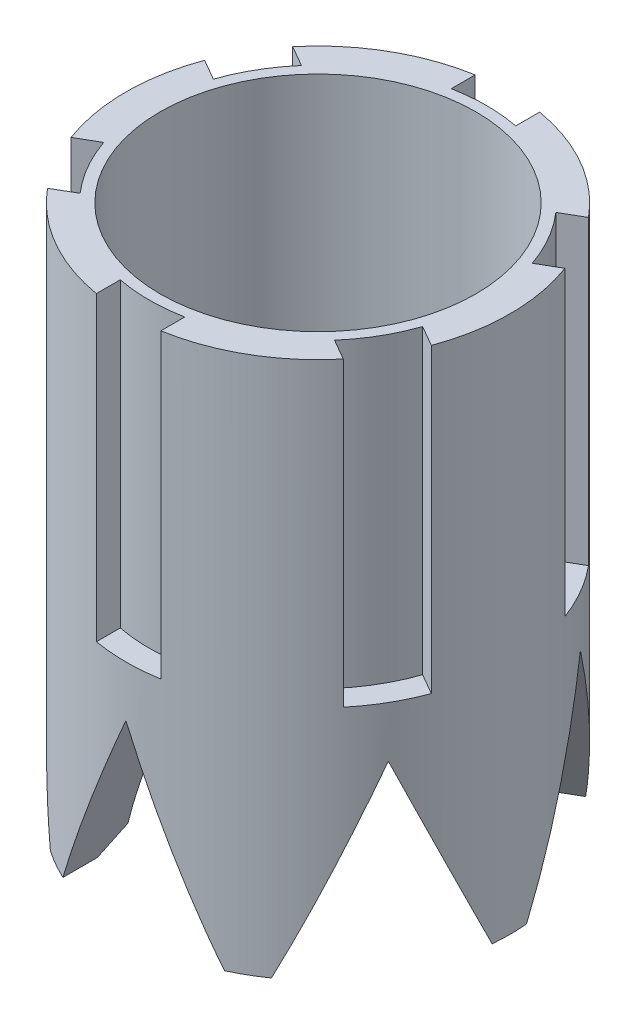
from build123d import *

# Parameters (mm, degrees)
SKETCH1_R           = 5.065
SKETCH1_R_2         = 3.67
BOSS_EXTRUDE1_DEPTH = 14.17
CUT_EXTRUDE1_DEPTH  = 7.95
SKETCH3_R           = 4.160986794
CUT_EXTRUDE2_DEPTH  = 7.59
CUT_EXTRUDE4_DEPTH  = 5.065
CIRPATTERN2_COUNT   = 6


with BuildPart() as part:
    # Sketch1 → Boss-Extrude1 (new body)
    with BuildSketch(Plane(origin=(0, 0, 0), x_dir=(1, 0, 0), z_dir=(0, 1, 0))):
        Circle(SKETCH1_R)
        Circle(SKETCH1_R_2, mode=Mode.SUBTRACT)
    extrude(amount=BOSS_EXTRUDE1_DEPTH)

    # Sketch2 → Cut-Extrude1 (cut)
    with BuildSketch(Plane(origin=(0, 14.17, 0), x_dir=(1, 0, 0), z_dir=(0, 1, 0))):
        with BuildLine():
            Line((-0.85, 4.362972037), (-0.85, 4.993167832))
            ThreePointArc((-0.85, 4.993167832), (0, 5.065), (0.85, 4.993167832))
            Line((0.85, 4.993167832), (0.85, 4.362972037))
            ThreePointArc((0.85, 4.362972037), (0, 4.445), (-0.85, 4.362972037))
        make_face()
        with BuildLine():
            Line((3.35344462, 2.917607612), (3.899210188, 3.232705509))
            ThreePointArc((3.899210188, 3.232705509), (4.38641867, 2.5325), (4.749210188, 1.760462323))
            Line((4.749210188, 1.760462323), (4.20344462, 1.445364426))
            ThreePointArc((4.20344462, 1.445364426), (3.84948292, 2.2225), (3.35344462, 2.917607612))
        make_face()
        with BuildLine():
            Line((4.20344462, -1.445364426), (4.749210188, -1.760462323))
            ThreePointArc((4.749210188, -1.760462323), (4.38641867, -2.5325), (3.899210188, -3.232705509))
            Line((3.899210188, -3.232705509), (3.35344462, -2.917607612))
            ThreePointArc((3.35344462, -2.917607612), (3.84948292, -2.2225), (4.20344462, -1.445364426))
        make_face()
        with BuildLine():
            Line((0.85, -4.362972037), (0.85, -4.993167832))
            ThreePointArc((0.85, -4.993167832), (0, -5.065), (-0.85, -4.993167832))
            Line((-0.85, -4.993167832), (-0.85, -4.362972037))
            ThreePointArc((-0.85, -4.362972037), (0, -4.445), (0.85, -4.362972037))
        make_face()
        with BuildLine():
            Line((-3.35344462, -2.917607612), (-3.899210188, -3.232705509))
            ThreePointArc((-3.899210188, -3.232705509), (-4.38641867, -2.5325), (-4.749210188, -1.760462323))
            Line((-4.749210188, -1.760462323), (-4.20344462, -1.445364426))
            ThreePointArc((-4.20344462, -1.445364426), (-3.84948292, -2.2225), (-3.35344462, -2.917607612))
        make_face()
        with BuildLine():
            Line((-4.20344462, 1.445364426), (-4.749210188, 1.760462323))
            ThreePointArc((-4.749210188, 1.760462323), (-4.38641867, 2.5325), (-3.899210188, 3.232705509))
            Line((-3.899210188, 3.232705509), (-3.35344462, 2.917607612))
            ThreePointArc((-3.35344462, 2.917607612), (-3.84948292, 2.2225), (-4.20344462, 1.445364426))
        make_face()
    extrude(amount=-CUT_EXTRUDE1_DEPTH, mode=Mode.SUBTRACT)

    # Sketch3 → Cut-Extrude2 (cut)
    with BuildSketch(Plane(origin=(0, 14.17, 0), x_dir=(1, 0, 0), z_dir=(0, 1, 0))):
        Circle(SKETCH3_R)
    extrude(amount=-CUT_EXTRUDE2_DEPTH, mode=Mode.SUBTRACT)

    # Sketch5 → Cut-Extrude4 (cut)
    with BuildSketch(Plane.XY):
        Polygon((0, 4.88), (-2.13, 0), (2.13, 0), align=None)
    cut_extrude4 = extrude(amount=-CUT_EXTRUDE4_DEPTH, mode=Mode.SUBTRACT)

    # CirPattern2: Cut-Extrude4 ×6 about axis
    cirpattern2_axis = Axis((0, 0, 0), (0, 1, 0))
    for i in range(1, CIRPATTERN2_COUNT):
        add(cut_extrude4.rotate(cirpattern2_axis, i * 360 / CIRPATTERN2_COUNT), mode=Mode.SUBTRACT)


solid = part.part
